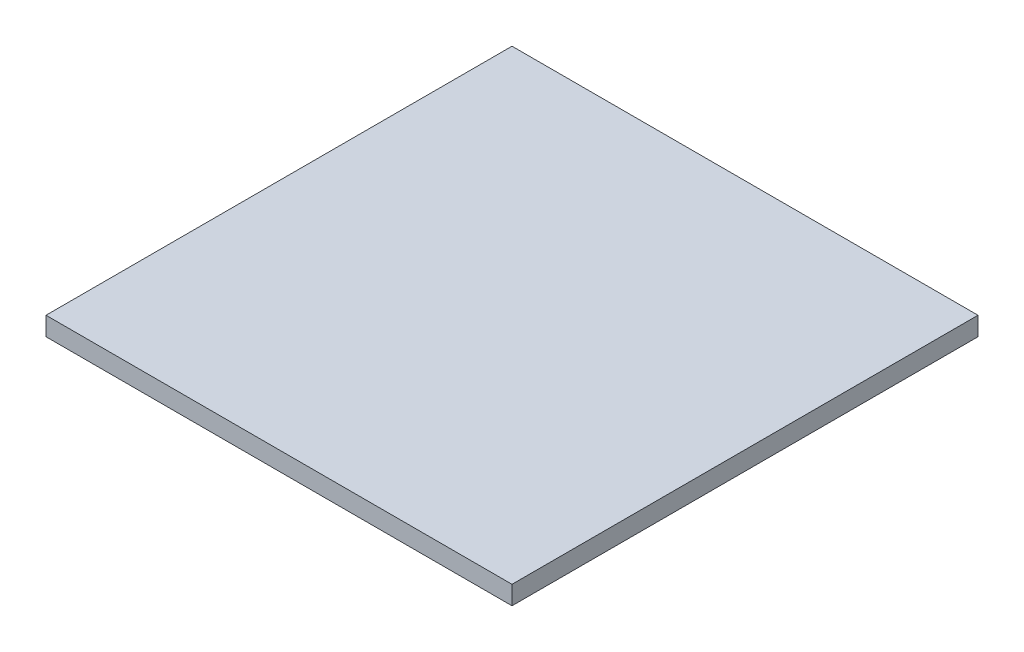
from build123d import *

# Parameters (mm, degrees)
SKETCH1_W           = 300
SKETCH1_H           = 300
BOSS_EXTRUDE1_DEPTH = 12


with BuildPart() as part:
    # Sketch1 → Boss-Extrude1 (new body)
    with BuildSketch(Plane(origin=(0, 0, 0), x_dir=(1, 0, 0), z_dir=(0, 1, 0))):
        Rectangle(SKETCH1_W, SKETCH1_H)
    extrude(amount=BOSS_EXTRUDE1_DEPTH)


solid = part.part
